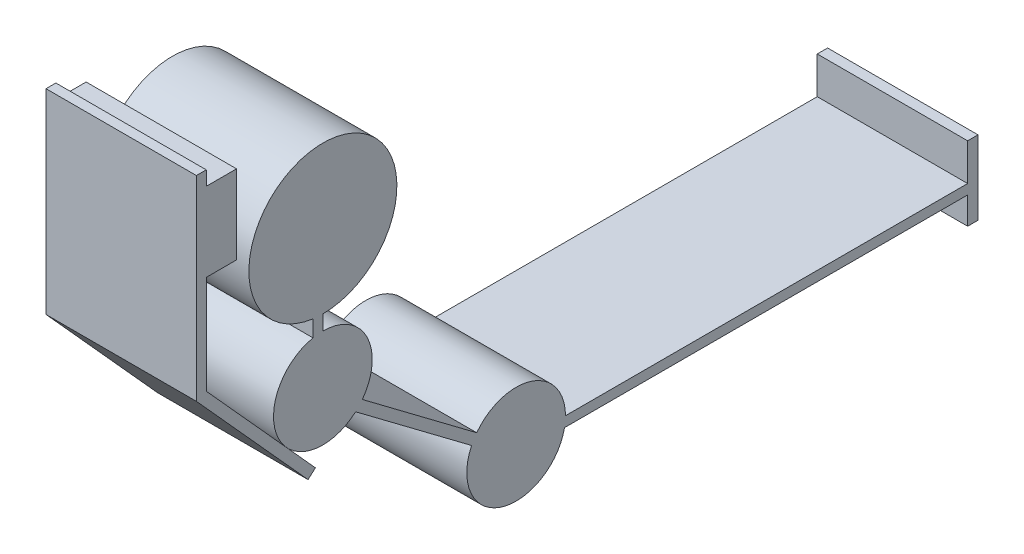
from build123d import *

# Parameters (mm, degrees)
BOSS_EXTRUDE1_DEPTH   = 304.8
BOSS_EXTRUDE1_2_DEPTH = 304.8


with BuildPart() as part:
    # Sketch1 → Boss-Extrude1 (new body)
    with BuildSketch(Plane(origin=(0, 0, 0), x_dir=(0, 0, -1), z_dir=(1, 0, 0))):
        with BuildLine():
            ThreePointArc((-862.590908506, -8.115598213), (-793.94700601, -40.940083443), (-722.076007022, -15.960257887))
            Line((-722.076007022, -15.960257887), (-487.048137736, -192.65747016))
            ThreePointArc((-487.048137736, -192.65747016), (-428.391943484, -330.400002986), (-298.734565156, -255.550028245))
            Line((-298.734565156, -255.550028245), (518.285845133, -255.550028245))
            Line((518.285845133, -255.550028245), (518.285845133, -310.550028245))
            Line((518.285845133, -310.550028245), (539.267073435, -310.550028245))
            Line((539.267073435, -310.550028245), (539.267073435, -160.550028245))
            Line((539.267073435, -160.550028245), (518.285845133, -160.550028245))
            Line((518.285845133, -160.550028245), (518.285845133, -235.550028245))
            Line((518.285845133, -235.550028245), (-296.714154867, -235.550028245))
            ThreePointArc((-296.714154867, -235.550028245), (-365.036366251, -140.700053504), (-476.644509035, -175.457279243))
            Line((-476.644509035, -175.457279243), (-708.442536122, -1.188307137))
            ThreePointArc((-708.442536122, -1.188307137), (-698.904250811, 103.573923056), (-788.37289029, 158.904441865))
            Line((-788.37289029, 158.904441865), (-788.37289029, 188.904441865))
            ThreePointArc((-788.37289029, 188.904441865), (-778.350493395, 488.569239197), (-808.37289029, 190.243754392))
            Line((-808.37289029, 190.243754392), (-808.37289029, 156.884031576))
            ThreePointArc((-808.37289029, 156.884031576), (-883.375407081, 90.121773641), (-862.590908506, -8.115598213))
        make_face()
    extrude(amount=BOSS_EXTRUDE1_DEPTH)


with BuildPart() as body_2:
    # Sketch1 → Boss-Extrude1 2 (new body)
    with BuildSketch(Plane(origin=(0, 0, 0), x_dir=(0, 0, -1), z_dir=(1, 0, 0))):
        Polygon((-1024.688746425, 171.391607246), (-1024.688746425, 371.220407618), (-963.37289029, 371.220407618), (-963.37289029, 531.070196922), (-1024.688746425, 531.070196922), (-1024.688746425, 559.971929091), (-1044.688746425, 559.971929091), (-1044.688746425, 163.697794457), (-818.373089049, -86.924247939), (-803.529485508, -73.520239811), (-862.590908506, -8.115598213), align=None)
    extrude(amount=BOSS_EXTRUDE1_2_DEPTH)


solid = Compound([part.part, body_2.part])
